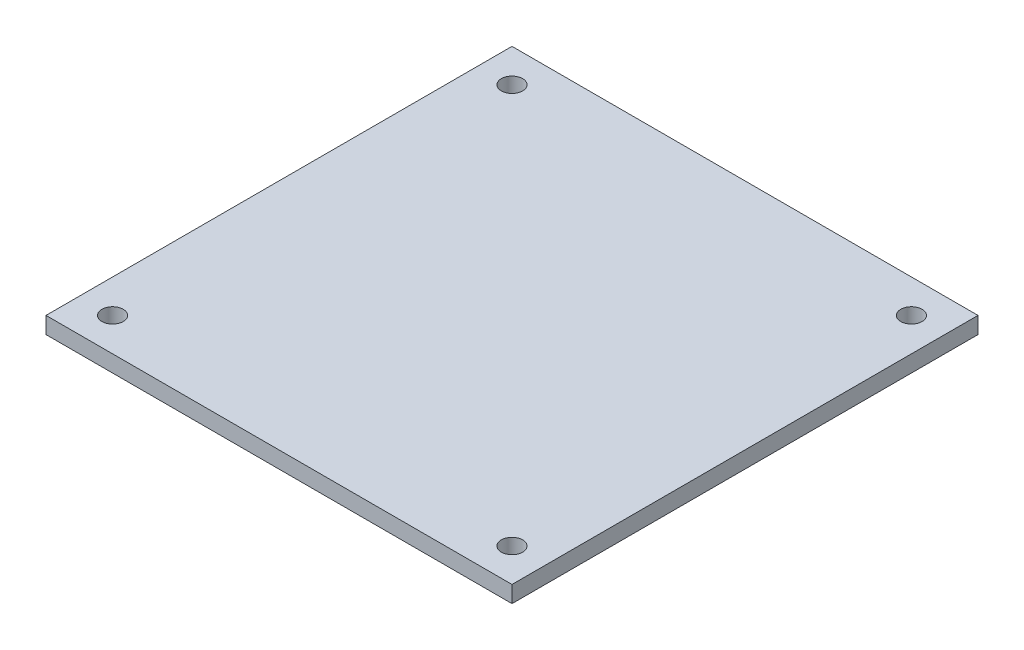
from build123d import *

# Parameters (mm, degrees)
SKETCH1_W           = 88.9
SKETCH1_H           = 88.9
SKETCH1_R           = 2.032
BOSS_EXTRUDE2_DEPTH = 3.175


with BuildPart() as part:
    # Sketch1 → Boss-Extrude2 (new body)
    with BuildSketch(Plane(origin=(0, 0, 0), x_dir=(1, 0, 0), z_dir=(0, 1, 0))):
        Rectangle(SKETCH1_W, SKETCH1_H)
        with Locations((-38.1, -38.1)):
            Circle(SKETCH1_R, mode=Mode.SUBTRACT)
        with Locations((38.1, 38.1)):
            Circle(SKETCH1_R, mode=Mode.SUBTRACT)
        with Locations((38.1, -38.1)):
            Circle(SKETCH1_R, mode=Mode.SUBTRACT)
        with Locations((-38.1, 38.1)):
            Circle(SKETCH1_R, mode=Mode.SUBTRACT)
    extrude(amount=BOSS_EXTRUDE2_DEPTH)


solid = part.part
